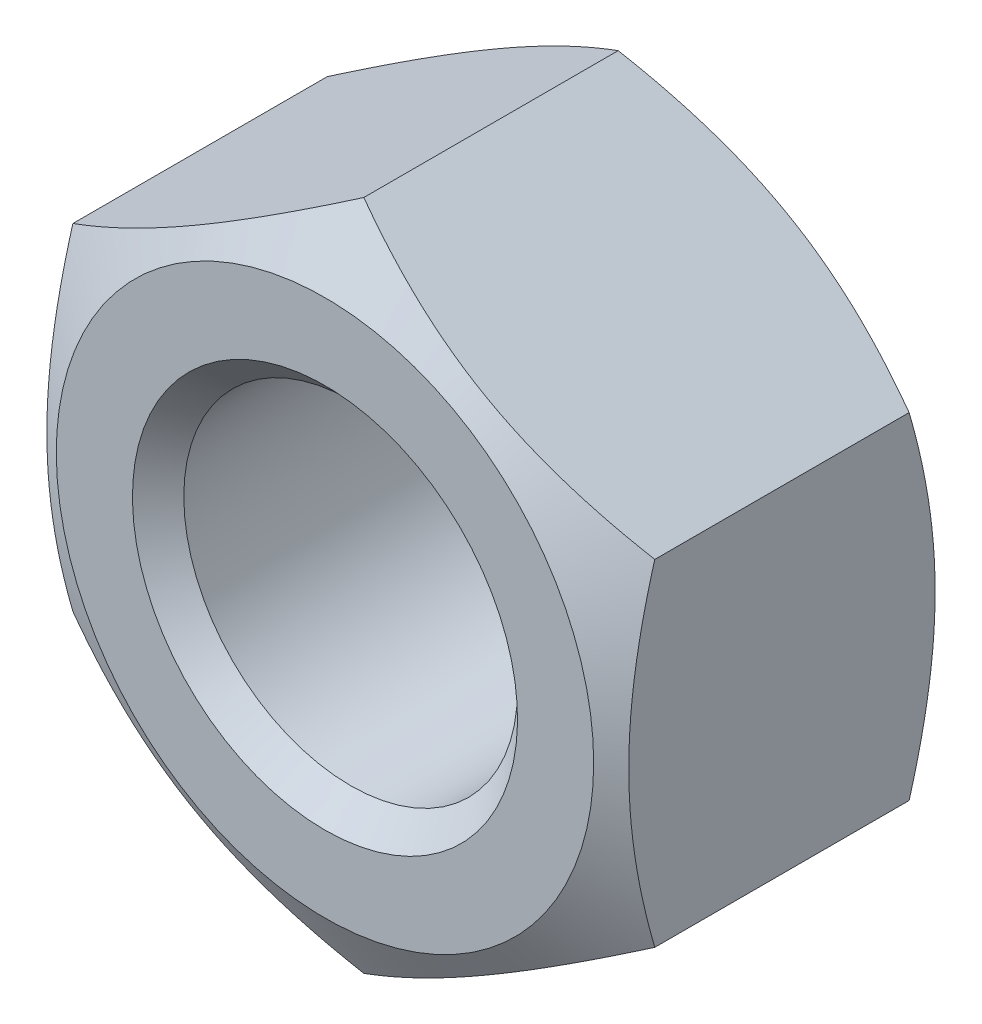
from build123d import *

# Parameters (mm, degrees)
BOSS_EXTRUDE1_DEPTH = 19.4


with BuildPart() as part:
    # Sketch1 → Boss-Extrude1 (new body)
    with BuildSketch(Plane.XY):
        Polygon((0, 19.629909152), (-17, 9.814954576), (-17, -9.814954576), (0, -19.629909152), (17, -9.814954576), (17, 9.814954576), align=None)
    extrude(amount=-BOSS_EXTRUDE1_DEPTH)

    # Sketch4 → Cut-Revolve1 (revolve, cut)
    with BuildSketch(Plane(origin=(0, 0, 0), x_dir=(0, 0, -1), z_dir=(1, 0, 0))):
        Polygon((19.4, 19.629909152), (17.131065893, 19.629909152), (19.4, 15.7), align=None)
        Polygon((0, 19.629909152), (2.268934107, 19.629909152), (0, 15.7), align=None)
    revolve(axis=Axis((0, 0, 0), (0, 0, -1)), mode=Mode.SUBTRACT)

    # Sketch5 → Cut-Revolve2 (revolve, cut)
    with BuildSketch(Plane(origin=(0, 0, 0), x_dir=(0, 0, -1), z_dir=(1, 0, 0))):
        Polygon((0, 0), (0, 11.25), (1.5, 9.75), (17.9, 9.75), (19.4, 11.25), (19.4, 0), align=None)
    revolve(axis=Axis((0, 0, 0), (0, 0, -1)), mode=Mode.SUBTRACT)


solid = part.part
